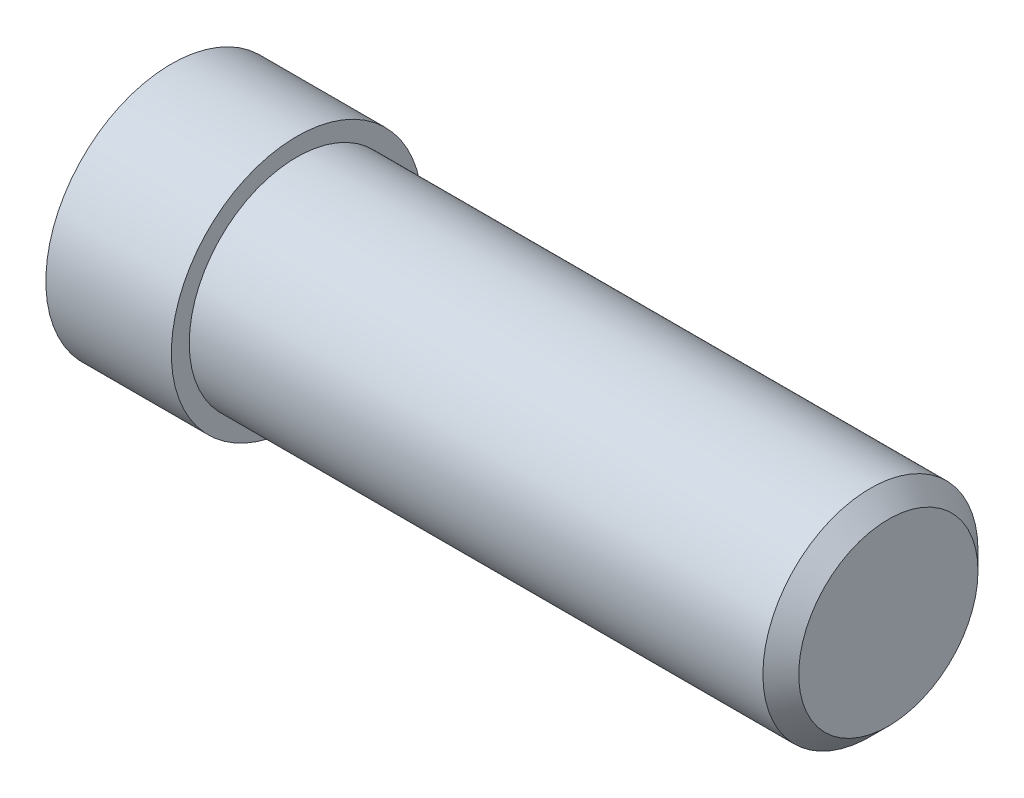
from build123d import *

# Parameters (mm, degrees)
PAH1_SIZE = 1


with BuildPart() as part:
    # Çizim1 → Döndür1 (revolve)
    with BuildSketch(Plane.XY):
        Polygon((0, 0), (0, 7), (7, 7), (7, 6), (40, 6), (40, 0), align=None)
    revolve(axis=Axis((49.559302541, 0, 0), (-1, 0, 0)))

    # Pah1
    pah1_edges = [part.edges().sort_by_distance(p)[0] for p in [
        (40, -6, 0),
    ]]
    chamfer(pah1_edges, length=PAH1_SIZE)


solid = part.part
